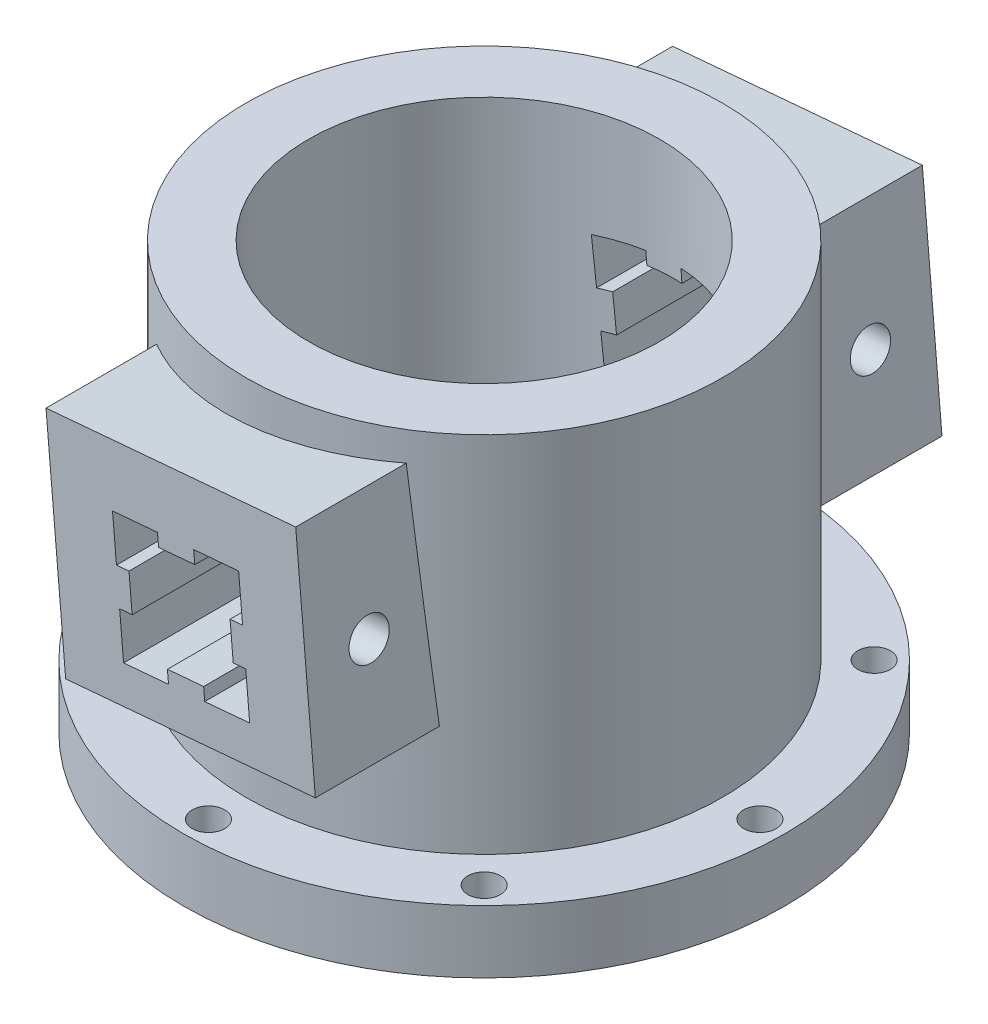
from build123d import *

# Parameters (mm, degrees)
ESQUISSE4_R                = 1.3
FIXINGHOLE_DEPTH           = 35
FIXINGHOLEREPETITION_COUNT = 8
RIGHTFIXING_DEPTH          = 10
ESQUISSE7_R                = 1.6
TOPFIXINGHOLES_DEPTH       = 8.6
HOLEFORFIXING_DEPTH        = 51


with BuildPart() as part:
    # Esquisse1 → Révolution1 (revolve)
    with BuildSketch(Plane.XY):
        Polygon((14, 0), (14, 34), (19, 34), (19, 5), (24, 5), (24, 0), align=None)
    revolve(axis=Axis((0, -1.825, 0), (0, 1, 0)))

    # Esquisse4 → FixingHole (cut, through all)
    with BuildSketch(Plane(origin=(0, 0, 0), x_dir=(-1, 0, 0), z_dir=(0, -1, 0))):
        with Locations((0, -22)):
            Circle(ESQUISSE4_R)
    fixinghole = extrude(amount=-FIXINGHOLE_DEPTH, mode=Mode.SUBTRACT)

    # FixingHoleRepetition: FixingHole ×8 about axis
    fixingholerepetition_axis = Axis((0, 0, 0), (0, 1, 0))
    for i in range(1, FIXINGHOLEREPETITION_COUNT):
        add(fixinghole.rotate(fixingholerepetition_axis, i * 360 / FIXINGHOLEREPETITION_COUNT), mode=Mode.SUBTRACT)

    # Esquisse5 → RightFixing (add)
    with BuildSketch(Plane.XY.offset(15)):
        Polygon((9.961946981, 31.674619421), (11.53075035, 13.743114855), (-8.393143611, 12), (-9.961946981, 29.931504566), align=None)
        Polygon((5.40803663, 26.357486686), (5.721797304, 22.771185773), (4.724085983, 22.683897343), (4.976837637, 19.794932719), (5.974548958, 19.882221149), (6.288309632, 16.295920235), (2.702008719, 15.982159562), (2.614720288, 16.979870883), (-0.274244336, 16.727119229), (-0.186955906, 15.729407908), (-3.773256819, 15.415647234), (-4.087017493, 19.001948147), (-3.089306172, 19.089236577), (-3.342057826, 21.978201201), (-4.339769147, 21.890912771), (-4.653529821, 25.477213684), (-1.067228908, 25.790974358), (-0.979940478, 24.793263037), (1.909024147, 25.046014691), (1.821735717, 26.043726012), align=None, mode=Mode.SUBTRACT)
    rightfixing = extrude(amount=RIGHTFIXING_DEPTH)

    # Esquisse7 → TopFixingHoles (cut)
    with BuildSketch(Plane(origin=(12.636394772, 1.10554129, 0), x_dir=(0, 0, -1), z_dir=(0.996194698, 0.087155743, 0))):
        with Locations((-20, 20.835847043)):
            Circle(ESQUISSE7_R)
    topfixingholes = extrude(amount=-TOPFIXINGHOLES_DEPTH, mode=Mode.SUBTRACT)

    # FixingSymetry: RightFixing, TopFixingHoles across plane
    add(rightfixing.mirror(Plane.XY))
    add(topfixingholes.mirror(Plane.XY), mode=Mode.SUBTRACT)

    # Esquisse6 → HoleForFixing (cut, through all)
    with BuildSketch(Plane.XY.offset(25)):
        Polygon((5.40803663, 26.357486686), (5.721797304, 22.771185773), (4.724085983, 22.683897343), (4.976837637, 19.794932719), (5.974548958, 19.882221149), (6.288309632, 16.295920235), (2.702008719, 15.982159562), (2.614720288, 16.979870883), (-0.274244336, 16.727119229), (-0.186955906, 15.729407908), (-3.773256819, 15.415647234), (-4.087017493, 19.001948147), (-3.089306172, 19.089236577), (-3.342057826, 21.978201201), (-4.339769147, 21.890912771), (-4.653529821, 25.477213684), (-1.067228908, 25.790974358), (-0.979940478, 24.793263037), (1.909024147, 25.046014691), (1.821735717, 26.043726012), align=None)
    extrude(amount=-HOLEFORFIXING_DEPTH, mode=Mode.SUBTRACT)


solid = part.part
